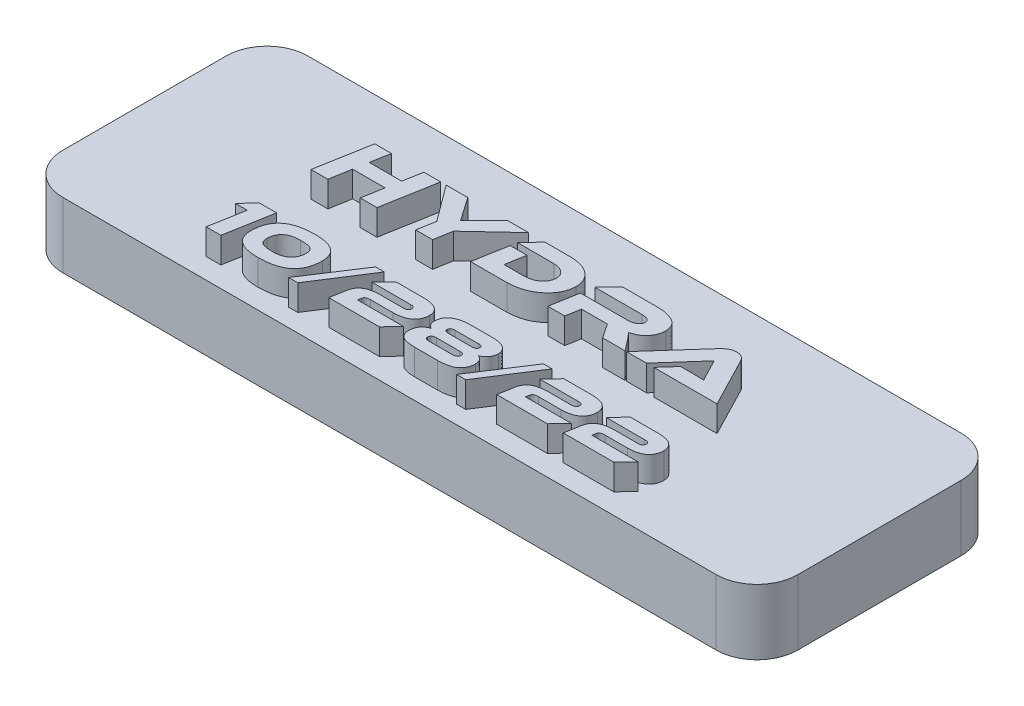
from build123d import *

# Parameters (mm, degrees)
SKETCH1_W           = 57.15
SKETCH1_H           = 19.05
BOSS_EXTRUDE1_DEPTH = 5.08
FILLET1_R           = 3.175
BOSS_EXTRUDE2_DEPTH = 2
SKETCH4_R           = 0.9
CUT_EXTRUDE1_DEPTH  = 4


with BuildPart() as part:
    # Sketch1 → Boss-Extrude1 (new body)
    with BuildSketch(Plane(origin=(0, 0, 0), x_dir=(1, 0, 0), z_dir=(0, 1, 0))):
        Rectangle(SKETCH1_W, SKETCH1_H)
    extrude(amount=BOSS_EXTRUDE1_DEPTH)

    # Fillet1
    fillet1_edges = [part.edges().sort_by_distance(p)[0] for p in [
        (-28.575, 2.54, -9.525),
        (-28.575, 2.54, 9.525),
        (28.575, 2.54, 9.525),
        (28.575, 2.54, -9.525),
    ]]
    fillet(fillet1_edges, radius=FILLET1_R)

    # Sketch3 → Boss-Extrude2 (add)
    with BuildSketch(Plane(origin=(0, 5.08, 0), x_dir=(1, 0, 0), z_dir=(0, 1, 0))):
        with BuildLine():
            Line((15.936649786, 0.006075914), (13.971522732, 3.800574494))
            add(Edge.make_bspline(
                [(13.971522732, 3.800574494), (13.953401788, 3.832806008), (13.917443125, 3.896765269), (13.852569435, 3.985575321), (13.775309948, 4.0630874), (13.690407037, 4.133983071), (13.592601143, 4.192399523), (13.480489993, 4.23493807), (13.354448166, 4.260058315), (13.265717233, 4.264204191), (13.219589517, 4.266359469)],
                knots=[0, 0, 0, 0, 0.000110886, 0.000220038, 0.000328642, 0.000438436, 0.000551159, 0.000668641, 0.000796469, 0.000934872, 0.000934872, 0.000934872, 0.000934872], degree=3))
            add(Edge.make_bspline(
                [(13.219589517, 4.266359469), (13.169777857, 4.264009128), (13.073046736, 4.259444915), (12.933007981, 4.230967468), (12.802729419, 4.187726952), (12.682994543, 4.126959855), (12.573312888, 4.055096369), (12.470111534, 3.977511138), (12.375805321, 3.892229282), (12.318422818, 3.830720556), (12.2898943, 3.800140628)],
                knots=[0, 0, 0, 0, 0.00014941, 0.000290146, 0.000427171, 0.000560039, 0.000691642, 0.000820174, 0.000947034, 0.001072464, 0.001072464, 0.001072464, 0.001072464], degree=3))
            Line((12.2898943, 3.800140628), (8.903896053, 0.006075914))
            Line((8.903896053, 0.006075914), (10.451986498, 0.006075914))
            Line((10.451986498, 0.006075914), (12.928931208, 2.798493231))
            Line((12.928931208, 2.798493231), (13.491298758, 1.696826253))
            add(Edge.make_bspline(
                [(13.491298758, 1.696826253), (13.517972762, 1.644325557), (13.572489009, 1.5370248), (13.641917351, 1.403208105), (13.698000445, 1.297464771), (13.739141559, 1.223921613), (13.775545401, 1.155498073), (13.800843706, 1.112747401), (13.812875845, 1.092414734)],
                knots=[0, 0, 0, 0, 0.000176664, 0.000361065, 0.000452265, 0.000535729, 0.000613867, 0.000684736, 0.000684736, 0.000684736, 0.000684736], degree=3))
            add(Edge.make_bspline(
                [(13.812875845, 1.092414734), (13.757427501, 1.095166522), (13.639267666, 1.101030553), (13.45483713, 1.103502684), (13.259818264, 1.10564963), (13.127565667, 1.105358474), (13.061440773, 1.105212899)],
                knots=[0, 0, 0, 0, 0.000166537, 0.000354888, 0.000553268, 0.00075164, 0.00075164, 0.00075164, 0.00075164], degree=3))
            Line((13.061440773, 1.105212899), (12.006395678, 1.105536066))
            Line((12.006395678, 1.105536066), (11.020672783, 0.006075914))
            Line((11.020672783, 0.006075914), (15.936649786, 0.006075914))
        make_face()
        with BuildLine():
            add(Edge.make_bspline(
                [(8.155110601, 0.821261664), (8.127324476, 0.855514425), (8.074414905, 0.920737585), (8.000629565, 1.014147602), (7.932026379, 1.094728322), (7.871660288, 1.165931133), (7.815679153, 1.228233858), (7.764174777, 1.283693514), (7.715591894, 1.332710365), (7.683288019, 1.361916294), (7.667928696, 1.375802657)],
                knots=[0, 0, 0, 0, 0.000132319, 0.000251958, 0.000357066, 0.000449775, 0.000531993, 0.000608312, 0.000676831, 0.00073894, 0.00073894, 0.00073894, 0.00073894], degree=3))
            add(Edge.make_bspline(
                [(7.667928696, 1.375802657), (7.718373618, 1.387655917), (7.817706328, 1.41099655), (7.961673348, 1.456505146), (8.09751208, 1.512656797), (8.225481623, 1.577599655), (8.346268229, 1.650662326), (8.457992649, 1.734287933), (8.561730528, 1.827209607), (8.657285995, 1.928008098), (8.74315281, 2.036209783), (8.819366418, 2.148795776), (8.882612688, 2.26744033), (8.936278633, 2.389702633), (8.976781015, 2.517720245), (9.008934795, 2.649747841), (9.02654449, 2.787111939), (9.030675934, 2.88015474), (9.032761498, 2.927122995)],
                knots=[0, 0, 0, 0, 0.000155422, 0.000306047, 0.000452383, 0.000595882, 0.000736201, 0.000875336, 0.001013884, 0.001153561, 0.001291475, 0.00142788, 0.00156081, 0.001694289, 0.00182785, 0.001963107, 0.002101444, 0.002242464, 0.002242464, 0.002242464, 0.002242464], degree=3))
            add(Edge.make_bspline(
                [(9.032761498, 2.927122995), (9.028097851, 2.986733362), (9.01909889, 3.101757358), (8.982692723, 3.266295736), (8.930107082, 3.416602664), (8.859145617, 3.55250609), (8.770617398, 3.674215745), (8.662815655, 3.779555576), (8.539470115, 3.872802597), (8.397838356, 3.946152329), (8.248044709, 4.009923214), (8.093755339, 4.066098529), (7.935637523, 4.111445148), (7.77464989, 4.149301444), (7.610082555, 4.17747869), (7.442540316, 4.196572697), (7.271932823, 4.207081738), (7.157234264, 4.20637971), (7.099324541, 4.206025266)],
                knots=[0, 0, 0, 0, 0.000179195, 0.000345775, 0.000503934, 0.000655634, 0.000804102, 0.000953423, 0.00110627, 0.001266195, 0.001430402, 0.00159465, 0.001758393, 0.001923592, 0.002090563, 0.002258951, 0.002429281, 0.002602973, 0.002602973, 0.002602973, 0.002602973], degree=3))
            Line((7.099324541, 4.206025266), (4.382824906, 4.206347541))
            Line((4.382824906, 4.206347541), (3.333914646, 3.106887389))
            Line((3.333914646, 3.106887389), (7.011419293, 3.106887389))
            add(Edge.make_bspline(
                [(7.011419293, 3.106887389), (7.059380843, 3.105563142), (7.150192599, 3.103055777), (7.27829741, 3.084102014), (7.389917703, 3.053127658), (7.484277277, 3.008361144), (7.560443595, 2.950733271), (7.616180007, 2.878524615), (7.649406671, 2.792039639), (7.653172018, 2.729960255), (7.655130531, 2.697670193)],
                knots=[0, 0, 0, 0, 0.000143839, 0.000272348, 0.000387495, 0.000490117, 0.000583924, 0.00067132, 0.000760449, 0.00085706, 0.00085706, 0.00085706, 0.00085706], degree=3))
            add(Edge.make_bspline(
                [(7.655130531, 2.697670193), (7.653453492, 2.677195647), (7.650145501, 2.636809238), (7.637364263, 2.578009425), (7.617255786, 2.522994029), (7.589864845, 2.47158108), (7.556473468, 2.423095084), (7.514536534, 2.378841184), (7.465518398, 2.338813063), (7.391840184, 2.288346001), (7.287225806, 2.236864834), (7.149746628, 2.191707585), (6.999141191, 2.165412454), (6.894656266, 2.161339559), (6.840618792, 2.15923314)],
                knots=[0, 0, 0, 0, 6.1582e-05, 0.000121471, 0.000179891, 0.000236731, 0.000295819, 0.000355966, 0.000418937, 0.000485369, 0.000623551, 0.000766937, 0.000918284, 0.001080402, 0.001080402, 0.001080402, 0.001080402], degree=3))
            Line((6.840618792, 2.15923314), (3.16330876, 2.159459893))
            Line((3.16330876, 2.159459893), (2.784184569, 0.003655726))
            Line((2.784184569, 0.003655726), (4.092163026, 0.003655726))
            Line((4.092163026, 0.003655726), (4.288043858, 1.11686837))
            Line((4.288043858, 1.11686837), (6.297402068, 1.11686837))
            Line((6.297402068, 1.11686837), (7.043012975, 0.003655726))
            Line((7.043012975, 0.003655726), (8.793302988, 0.003655726))
            Line((8.793302988, 0.003655726), (8.155110601, 0.821261664))
        make_face()
        with BuildLine():
            add(Edge.make_bspline(
                [(2.55867763, 2.425376215), (2.555801916, 2.490366785), (2.550151506, 2.618064917), (2.518344126, 2.803986167), (2.469713518, 2.980115123), (2.404179951, 3.146960648), (2.317982795, 3.303299496), (2.214551164, 3.450058323), (2.092308783, 3.586303096), (1.95374969, 3.712179584), (1.798742287, 3.825344313), (1.630327922, 3.925395962), (1.448112387, 4.009390478), (1.25324885, 4.079106767), (1.045179008, 4.133528035), (0.823979956, 4.173811565), (0.589540311, 4.198189582), (0.428794296, 4.203371321), (0.346464589, 4.206025266)],
                knots=[0, 0, 0, 0, 0.000195009, 0.000383167, 0.000564368, 0.00074244, 0.000919581, 0.001098646, 0.001279935, 0.00146761, 0.001659228, 0.001854731, 0.002054318, 0.002260196, 0.002474835, 0.002698788, 0.00293411, 0.003181175, 0.003181175, 0.003181175, 0.003181175], degree=3))
            Line((0.346464589, 4.206025266), (-1.649600884, 4.206347541))
            Line((-1.649600884, 4.206347541), (-2.679554935, 3.106887389))
            Line((-2.679554935, 3.106887389), (0.151239021, 3.106887389))
            add(Edge.make_bspline(
                [(0.151239021, 3.106887389), (0.190750921, 3.105364711), (0.267967163, 3.102389015), (0.380588809, 3.089591847), (0.487281825, 3.069582481), (0.588130182, 3.04202105), (0.683492268, 3.008030543), (0.771622667, 2.964107485), (0.854485945, 2.914773344), (0.931249281, 2.858665576), (0.999163961, 2.795181395), (1.060842489, 2.72884043), (1.110672717, 2.655711823), (1.153486551, 2.579167986), (1.187717263, 2.49778013), (1.210713003, 2.411231968), (1.227244218, 2.320728819), (1.229970936, 2.258648084), (1.231366232, 2.22688058)],
                knots=[0, 0, 0, 0, 0.000118592, 0.000231759, 0.000339692, 0.000443921, 0.000545141, 0.000642853, 0.0007388, 0.00083424, 0.000927403, 0.001017368, 0.001105364, 0.001192113, 0.001280223, 0.00136938, 0.001460305, 0.001555592, 0.001555592, 0.001555592, 0.001555592], degree=3))
            add(Edge.make_bspline(
                [(1.231366232, 2.22688058), (1.228921788, 2.185642711), (1.224127048, 2.104755276), (1.201586347, 1.98706422), (1.168080093, 1.87545354), (1.120952623, 1.770616802), (1.061706994, 1.672112744), (0.991418602, 1.579018173), (0.906839413, 1.493971369), (0.812401326, 1.414841832), (0.708184046, 1.343689091), (0.596529197, 1.281927096), (0.478895742, 1.227960987), (0.353625987, 1.185692043), (0.222464649, 1.150471437), (0.084116555, 1.126576329), (-0.060210252, 1.109169924), (-0.15900863, 1.106548421), (-0.209341401, 1.105212899)],
                knots=[0, 0, 0, 0, 0.00012382, 0.000242871, 0.000358539, 0.000472706, 0.000586683, 0.000702784, 0.000821729, 0.000945681, 0.001071953, 0.001199634, 0.001328098, 0.001459638, 0.001595783, 0.001735109, 0.00188048, 0.002031451, 0.002031451, 0.002031451, 0.002031451], degree=3))
            Line((-0.209341401, 1.105212899), (-1.725425722, 1.105536066))
            Line((-1.725425722, 1.105536066), (-1.453720052, 2.623662059))
            Line((-1.453720052, 2.623662059), (-2.761698509, 2.623662059))
            Line((-2.761698509, 2.623662059), (-3.229285011, 0.006075914))
            Line((-3.229285011, 0.006075914), (-0.398491055, 0.006075914))
            add(Edge.make_bspline(
                [(-0.398491055, 0.006075914), (-0.296623679, 0.00973645), (-0.096467742, 0.016928919), (0.196909938, 0.055361686), (0.477503471, 0.113609118), (0.745379994, 0.192345638), (1.00082206, 0.290947451), (1.242998592, 0.411678855), (1.473449233, 0.551302588), (1.652823715, 0.685730436), (1.788110055, 0.801137626), (1.883300669, 0.891127884), (1.972791218, 0.98286194), (2.055684535, 1.077854124), (2.132445982, 1.175378809), (2.202621649, 1.275986307), (2.26734959, 1.378755373), (2.324479922, 1.484675691), (2.376054975, 1.592866707), (2.420943245, 1.703675086), (2.459150184, 1.817381495), (2.492247599, 1.933500983), (2.519103778, 2.052449268), (2.537580931, 2.174419147), (2.552013189, 2.298802205), (2.555862909, 2.38285802), (2.55867763, 2.425376215)],
                knots=[0, 0, 0, 0, 0.000305659, 0.00060058, 0.000886364, 0.001164634, 0.001437273, 0.001706688, 0.001975409, 0.002244537, 0.002378097, 0.002508729, 0.002637378, 0.002762417, 0.002886772, 0.003009517, 0.003130255, 0.003250927, 0.003370328, 0.003489667, 0.003609348, 0.003730019, 0.003851781, 0.003974869, 0.004099948, 0.004227226, 0.004227226, 0.004227226, 0.004227226], degree=3))
        make_face()
        with BuildLine():
            Line((-4.567350224, 4.208766837), (-5.736316477, 3.045937203))
            add(Edge.make_bspline(
                [(-5.736316477, 3.045937203), (-5.778994085, 3.002996199), (-5.859188805, 2.922306534), (-5.971803651, 2.808525621), (-6.070005467, 2.710170076), (-6.152996059, 2.624049414), (-6.224224472, 2.54963655), (-6.28673006, 2.48596507), (-6.339765089, 2.429919868), (-6.372273024, 2.395395347), (-6.387198116, 2.379544396)],
                knots=[0, 0, 0, 0, 0.000181625, 0.000341288, 0.000480267, 0.000598575, 0.000700079, 0.000789292, 0.000866239, 0.000931555, 0.000931555, 0.000931555, 0.000931555], degree=3))
            add(Edge.make_bspline(
                [(-6.387198116, 2.379544396), (-6.399005631, 2.400004032), (-6.425311188, 2.445585352), (-6.470825966, 2.520103953), (-6.530223445, 2.605177377), (-6.596015271, 2.700257958), (-6.66366472, 2.796857317), (-6.727383556, 2.887031312), (-6.784321541, 2.96668259), (-6.819605422, 3.016396767), (-6.836048019, 3.03956401)],
                knots=[0, 0, 0, 0, 7.0869e-05, 0.000157887, 0.000261844, 0.000382044, 0.000504789, 0.000615628, 0.000713289, 0.000798516, 0.000798516, 0.000798516, 0.000798516], degree=3))
            Line((-6.836048019, 3.03956401), (-7.644574903, 4.208766837))
            Line((-7.644574903, 4.208766837), (-9.325358814, 4.208766837))
            Line((-9.325358814, 4.208766837), (-7.246494503, 1.399082354))
            Line((-7.246494503, 1.399082354), (-7.492925226, 0.003655726))
            Line((-7.492925226, 0.003655726), (-6.178628033, 0.003655726))
            Line((-6.178628033, 0.003655726), (-5.938516046, 1.392796648))
            Line((-5.938516046, 1.392796648), (-2.924478732, 4.208766837))
            Line((-2.924478732, 4.208766837), (-4.567350224, 4.208766837))
        make_face()
        Polygon((-9.749790791, 4.208766837), (-11.057769248, 4.208766837), (-11.323156181, 2.743700198), (-13.844332048, 2.743700198), (-13.572626378, 4.208766837), (-14.880604835, 4.208766837), (-15.632534479, 0.003655726), (-14.318237286, 0.003655726), (-14.033894143, 1.644240046), (-11.512718276, 1.644240046), (-11.803380156, 0.003655726), (-10.501720435, 0.003655726), align=None)
        with BuildLine():
            Line((12.547539263, -5.218973535), (15.538671157, -5.218973535))
            add(Edge.make_bspline(
                [(15.538671157, -5.218973535), (15.566372071, -5.218922741), (15.618218446, -5.218827674), (15.690947449, -5.225918073), (15.75247149, -5.242216387), (15.804302027, -5.26353583), (15.844395417, -5.294908436), (15.872709416, -5.334273792), (15.890261393, -5.381008794), (15.891486093, -5.4147712), (15.892120459, -5.432259348)],
                knots=[0, 0, 0, 0, 8.3099e-05, 0.000155531, 0.000218392, 0.000273538, 0.000322508, 0.000368908, 0.000417497, 0.000469711, 0.000469711, 0.000469711, 0.000469711], degree=3))
            add(Edge.make_bspline(
                [(15.892120459, -5.432259348), (15.891480666, -5.458018948), (15.890271061, -5.506720508), (15.869708675, -5.573936821), (15.836422299, -5.630194031), (15.787208676, -5.673414306), (15.723677577, -5.704561408), (15.64594341, -5.726311626), (15.552818251, -5.738498194), (15.485816606, -5.73961472), (15.449783907, -5.740215175)],
                knots=[0, 0, 0, 0, 7.6993e-05, 0.000145564, 0.000208395, 0.000270703, 0.000339032, 0.00041902, 0.000511893, 0.000619952, 0.000619952, 0.000619952, 0.000619952], degree=3))
            Line((15.449783907, -5.740215175), (13.692020413, -5.739416071))
            add(Edge.make_bspline(
                [(13.692020413, -5.739416071), (13.636418257, -5.740560639), (13.528165095, -5.742789025), (13.370169769, -5.753609346), (13.221450409, -5.772857955), (13.081827541, -5.798779792), (12.951564343, -5.833149331), (12.830485491, -5.875619954), (12.718218111, -5.92500466), (12.615016243, -5.98174212), (12.521547046, -6.047028209), (12.437021553, -6.120143527), (12.361620944, -6.201107035), (12.295619922, -6.289606037), (12.239238349, -6.385733808), (12.192142594, -6.489539314), (12.153195231, -6.600822081), (12.135873555, -6.678800473), (12.127060513, -6.718474855)],
                knots=[0, 0, 0, 0, 0.000166829, 0.000324804, 0.000474816, 0.000616477, 0.000750546, 0.000878553, 0.001001026, 0.001118108, 0.001231277, 0.001342418, 0.001452782, 0.001562526, 0.00167296, 0.001786425, 0.001904052, 0.002025887, 0.002025887, 0.002025887, 0.002025887], degree=3))
            Line((12.127060513, -6.718474855), (11.911716402, -7.932183575))
            Line((11.911716402, -7.932183575), (15.848289246, -7.932183575))
            Line((15.848289246, -7.932183575), (16.755027935, -6.970155942))
            Line((16.755027935, -6.970155942), (13.183362124, -6.970155942))
            Line((13.183362124, -6.970155942), (13.233122174, -6.707239748))
            add(Edge.make_bspline(
                [(13.233122174, -6.707239748), (13.236899698, -6.686112106), (13.244222455, -6.645156023), (13.272933808, -6.590591717), (13.311294501, -6.543848716), (13.362633832, -6.508043577), (13.423709299, -6.47963759), (13.496026919, -6.461031101), (13.57909034, -6.450993538), (13.638013851, -6.450679637), (13.669239306, -6.450513291)],
                knots=[0, 0, 0, 0, 6.4036e-05, 0.000124134, 0.000182613, 0.000243892, 0.000310094, 0.000383827, 0.000466868, 0.000560486, 0.000560486, 0.000560486, 0.000560486], degree=3))
            Line((13.669239306, -6.450513291), (15.428093268, -6.449714187))
            add(Edge.make_bspline(
                [(15.428093268, -6.449714187), (15.493774293, -6.448593152), (15.621108734, -6.446419826), (15.805006583, -6.426694059), (15.976423193, -6.400940141), (16.134270079, -6.361961645), (16.280024073, -6.315052912), (16.411365328, -6.255202462), (16.530838443, -6.187512089), (16.635550883, -6.107690588), (16.728134075, -6.020066732), (16.808590437, -5.925525662), (16.876369321, -5.823724541), (16.932122123, -5.715194429), (16.974258093, -5.599220599), (17.004953528, -5.476792913), (17.022608874, -5.347458364), (17.024561827, -5.259004345), (17.02555788, -5.21389067)],
                knots=[0, 0, 0, 0, 0.00019697, 0.000381861, 0.000554393, 0.000716581, 0.000869107, 0.001013024, 0.00114885, 0.001280192, 0.001406932, 0.001530654, 0.001651783, 0.001773055, 0.001895792, 0.002021116, 0.002151095, 0.002286391, 0.002286391, 0.002286391, 0.002286391], degree=3))
            add(Edge.make_bspline(
                [(17.02555788, -5.21389067), (17.025105426, -5.1780961), (17.024219681, -5.108023129), (17.008009834, -5.005989197), (16.984017761, -4.909275966), (16.947483058, -4.818686266), (16.899848705, -4.734234215), (16.841769663, -4.655338408), (16.773402037, -4.582231577), (16.694107596, -4.515185386), (16.60328468, -4.455053695), (16.499706059, -4.402688892), (16.383472939, -4.359688685), (16.255285459, -4.322394884), (16.11448245, -4.294289614), (15.961135405, -4.27367202), (15.795268874, -4.26108405), (15.680439258, -4.258543735), (15.620959354, -4.257227893)],
                knots=[0, 0, 0, 0, 0.000107259, 0.000209975, 0.000309113, 0.00040566, 0.000501999, 0.00059927, 0.000698874, 0.0008016, 0.000910084, 0.001024914, 0.001148961, 0.001281358, 0.001425053, 0.00157924, 0.00174531, 0.001923772, 0.001923772, 0.001923772, 0.001923772], degree=3))
            Line((15.620959354, -4.257227893), (13.454277952, -4.256945902))
            Line((13.454277952, -4.256945902), (12.547539263, -5.218973535))
        make_face()
        with BuildLine():
            Line((7.377080905, -5.218973535), (10.3682128, -5.218973535))
            add(Edge.make_bspline(
                [(10.3682128, -5.218973535), (10.395913714, -5.218922741), (10.447760088, -5.218827674), (10.520489091, -5.225918073), (10.582013133, -5.242216387), (10.63384367, -5.26353583), (10.673937059, -5.294908436), (10.702251058, -5.334273792), (10.719803036, -5.381008794), (10.721027735, -5.4147712), (10.721662101, -5.432259348)],
                knots=[0, 0, 0, 0, 8.3099e-05, 0.000155531, 0.000218392, 0.000273538, 0.000322508, 0.000368908, 0.000417497, 0.000469711, 0.000469711, 0.000469711, 0.000469711], degree=3))
            add(Edge.make_bspline(
                [(10.721662101, -5.432259348), (10.721022308, -5.458018948), (10.719812703, -5.506720508), (10.699250318, -5.573936821), (10.665963942, -5.630194031), (10.616750318, -5.673414306), (10.55321922, -5.704561408), (10.475485053, -5.726311626), (10.382359893, -5.738498194), (10.315358249, -5.73961472), (10.27932555, -5.740215175)],
                knots=[0, 0, 0, 0, 7.6993e-05, 0.000145564, 0.000208395, 0.000270703, 0.000339032, 0.00041902, 0.000511893, 0.000619952, 0.000619952, 0.000619952, 0.000619952], degree=3))
            Line((10.27932555, -5.740215175), (8.521562055, -5.739416071))
            add(Edge.make_bspline(
                [(8.521562055, -5.739416071), (8.465959899, -5.740560639), (8.357706737, -5.742789025), (8.199711411, -5.753609346), (8.050992051, -5.772857955), (7.911369183, -5.798779792), (7.781105985, -5.833149331), (7.660027133, -5.875619954), (7.547759753, -5.92500466), (7.444557885, -5.98174212), (7.351088689, -6.047028209), (7.266563196, -6.120143527), (7.191162587, -6.201107035), (7.125161564, -6.289606037), (7.068779991, -6.385733808), (7.021684236, -6.489539314), (6.982736873, -6.600822081), (6.965415197, -6.678800473), (6.956602156, -6.718474855)],
                knots=[0, 0, 0, 0, 0.000166829, 0.000324804, 0.000474816, 0.000616477, 0.000750546, 0.000878553, 0.001001026, 0.001118108, 0.001231277, 0.001342418, 0.001452782, 0.001562526, 0.00167296, 0.001786425, 0.001904052, 0.002025887, 0.002025887, 0.002025887, 0.002025887], degree=3))
            Line((6.956602156, -6.718474855), (6.741258044, -7.932183575))
            Line((6.741258044, -7.932183575), (10.677830889, -7.932183575))
            Line((10.677830889, -7.932183575), (11.584569577, -6.970155942))
            Line((11.584569577, -6.970155942), (8.012903767, -6.970155942))
            Line((8.012903767, -6.970155942), (8.062663817, -6.707239748))
            add(Edge.make_bspline(
                [(8.062663817, -6.707239748), (8.06644134, -6.686112106), (8.073764097, -6.645156023), (8.10247545, -6.590591717), (8.140836143, -6.543848716), (8.192175475, -6.508043577), (8.253250942, -6.47963759), (8.325568562, -6.461031101), (8.408631983, -6.450993538), (8.467555493, -6.450679637), (8.498780948, -6.450513291)],
                knots=[0, 0, 0, 0, 6.4036e-05, 0.000124134, 0.000182613, 0.000243892, 0.000310094, 0.000383827, 0.000466868, 0.000560486, 0.000560486, 0.000560486, 0.000560486], degree=3))
            Line((8.498780948, -6.450513291), (10.257634911, -6.449714187))
            add(Edge.make_bspline(
                [(10.257634911, -6.449714187), (10.323315936, -6.448593152), (10.450650376, -6.446419826), (10.634548225, -6.426694059), (10.805964836, -6.400940141), (10.963811722, -6.361961645), (11.109565715, -6.315052912), (11.24090697, -6.255202462), (11.360380086, -6.187512089), (11.465092525, -6.107690588), (11.557675717, -6.020066732), (11.638132079, -5.925525662), (11.705910963, -5.823724541), (11.761663765, -5.715194429), (11.803799735, -5.599220599), (11.834495171, -5.476792913), (11.852150516, -5.347458364), (11.85410347, -5.259004345), (11.855099523, -5.21389067)],
                knots=[0, 0, 0, 0, 0.00019697, 0.000381861, 0.000554393, 0.000716581, 0.000869107, 0.001013024, 0.00114885, 0.001280192, 0.001406932, 0.001530654, 0.001651783, 0.001773055, 0.001895792, 0.002021116, 0.002151095, 0.002286391, 0.002286391, 0.002286391, 0.002286391], degree=3))
            add(Edge.make_bspline(
                [(11.855099523, -5.21389067), (11.854647068, -5.1780961), (11.853761323, -5.108023129), (11.837551476, -5.005989197), (11.813559404, -4.909275966), (11.777024701, -4.818686266), (11.729390348, -4.734234215), (11.671311306, -4.655338408), (11.602943679, -4.582231577), (11.523649239, -4.515185386), (11.432826322, -4.455053695), (11.329247701, -4.402688892), (11.213014581, -4.359688685), (11.084827102, -4.322394884), (10.944024093, -4.294289614), (10.790677047, -4.27367202), (10.624810516, -4.26108405), (10.509980901, -4.258543735), (10.450500996, -4.257227893)],
                knots=[0, 0, 0, 0, 0.000107259, 0.000209975, 0.000309113, 0.00040566, 0.000501999, 0.00059927, 0.000698874, 0.0008016, 0.000910084, 0.001024914, 0.001148961, 0.001281358, 0.001425053, 0.00157924, 0.00174531, 0.001923772, 0.001923772, 0.001923772, 0.001923772], degree=3))
            Line((10.450500996, -4.257227893), (8.283819594, -4.256945902))
            Line((8.283819594, -4.256945902), (7.377080905, -5.218973535))
        make_face()
        Polygon((6.491270465, -4.05005839), (3.826343343, -8.139071868), (4.539570726, -8.139071868), (7.165795587, -4.05005839), align=None)
        with BuildLine():
            add(Edge.make_bspline(
                [(2.145109496, -7.932183575), (2.186771054, -7.931231171), (2.268740703, -7.929357303), (2.389381902, -7.92303202), (2.504838313, -7.913299393), (2.615078713, -7.901630571), (2.71983482, -7.886120178), (2.819756863, -7.869023985), (2.914134147, -7.848038176), (3.003008373, -7.824924016), (3.086720734, -7.79951071), (3.165025248, -7.770456276), (3.238821837, -7.739757788), (3.306770407, -7.705166947), (3.369767071, -7.668342595), (3.427192994, -7.628415757), (3.479544276, -7.586096005), (3.540828281, -7.52618861), (3.608893469, -7.44788067), (3.679627769, -7.349322028), (3.738550042, -7.24731168), (3.785064676, -7.14179993), (3.820734635, -7.033385143), (3.843950971, -6.921252912), (3.855400575, -6.805633592), (3.853837653, -6.727559312), (3.853047325, -6.688079215)],
                knots=[0, 0, 0, 0, 0.000125013, 0.000245965, 0.000362345, 0.000472585, 0.000578466, 0.000679988, 0.000776639, 0.000868406, 0.000955443, 0.001038954, 0.001118882, 0.001195077, 0.00126751, 0.001337627, 0.001404712, 0.001469201, 0.001594487, 0.00171546, 0.001832632, 0.001947228, 0.002060803, 0.002174381, 0.002290108, 0.002408491, 0.002408491, 0.002408491, 0.002408491], degree=3))
            add(Edge.make_bspline(
                [(3.853047325, -6.688079215), (3.851078427, -6.645013118), (3.847289314, -6.562133096), (3.82207087, -6.444672392), (3.783411556, -6.339091581), (3.727319812, -6.248261694), (3.65963707, -6.170723555), (3.581913799, -6.10705473), (3.495368629, -6.055649416), (3.431736146, -6.034755311), (3.399512379, -6.024174444)],
                knots=[0, 0, 0, 0, 0.000129139, 0.000248525, 0.000358904, 0.000464809, 0.000566844, 0.000666291, 0.000765209, 0.000866693, 0.000866693, 0.000866693, 0.000866693], degree=3))
            add(Edge.make_bspline(
                [(3.399512379, -6.024174444), (3.440843035, -6.009960653), (3.524127185, -5.981318874), (3.640587349, -5.914739414), (3.750314358, -5.831227741), (3.835139045, -5.748532962), (3.896530116, -5.672798575), (3.937857181, -5.610121102), (3.971944913, -5.541280496), (4.001590849, -5.468161351), (4.025102653, -5.389726388), (4.041155488, -5.306040388), (4.053866343, -5.217443624), (4.056480977, -5.156345524), (4.057817953, -5.125103406)],
                knots=[0, 0, 0, 0, 0.000130881, 0.000263734, 0.000400196, 0.000543864, 0.000617818, 0.000692362, 0.000768557, 0.000847875, 0.000928857, 0.001013724, 0.001103318, 0.001197072, 0.001197072, 0.001197072, 0.001197072], degree=3))
            add(Edge.make_bspline(
                [(4.057817953, -5.125103406), (4.056597618, -5.090349443), (4.05422499, -5.022779311), (4.035525317, -4.92500398), (4.009013255, -4.833420282), (3.971040329, -4.748206931), (3.921670533, -4.670138756), (3.862202391, -4.59864822), (3.79215361, -4.533829851), (3.712283076, -4.475835581), (3.622758665, -4.424616933), (3.524902512, -4.38005075), (3.419062792, -4.341545727), (3.304813196, -4.310438157), (3.1823421, -4.286642109), (3.051645869, -4.270305953), (2.913087684, -4.259700382), (2.818015937, -4.258066688), (2.76920279, -4.257227893)],
                knots=[0, 0, 0, 0, 0.000104182, 0.000202555, 0.000297711, 0.000389729, 0.000481385, 0.000573968, 0.000667919, 0.000766953, 0.000869442, 0.000976817, 0.001089166, 0.001206956, 0.001331669, 0.001463128, 0.001601898, 0.001748332, 0.001748332, 0.001748332, 0.001748332], degree=3))
            Line((2.76920279, -4.257227893), (1.01721503, -4.256945902))
            add(Edge.make_bspline(
                [(1.01721503, -4.256945902), (0.955941016, -4.257933345), (0.83660449, -4.259856478), (0.662243978, -4.27445031), (0.497678332, -4.298184588), (0.342659552, -4.330928531), (0.197262899, -4.372216855), (0.061486281, -4.423370326), (-0.064498068, -4.48435463), (-0.18071126, -4.553771073), (-0.286111226, -4.631408275), (-0.376959488, -4.719750309), (-0.455817934, -4.815062538), (-0.51919052, -4.920560106), (-0.569956029, -5.033834732), (-0.606698648, -5.155860959), (-0.630309498, -5.286067538), (-0.634542773, -5.375899516), (-0.636708671, -5.421860839)],
                knots=[0, 0, 0, 0, 0.000183805, 0.000357976, 0.000524491, 0.000682313, 0.000832949, 0.000977498, 0.00111702, 0.001252279, 0.00138314, 0.001508725, 0.001631528, 0.001753207, 0.001876737, 0.002003, 0.002134641, 0.002272556, 0.002272556, 0.002272556, 0.002272556], degree=3))
            add(Edge.make_bspline(
                [(-0.636708671, -5.421860839), (-0.63454772, -5.460637769), (-0.630411686, -5.534856314), (-0.607913743, -5.640394087), (-0.572075057, -5.734319484), (-0.522817108, -5.816044843), (-0.462991867, -5.884580779), (-0.397584596, -5.942717951), (-0.327188617, -5.991372439), (-0.275336168, -6.0132839), (-0.249564203, -6.024174444)],
                knots=[0, 0, 0, 0, 0.00011638, 0.00022275, 0.000322273, 0.000416653, 0.000507404, 0.000594091, 0.000678837, 0.000762581, 0.000762581, 0.000762581, 0.000762581], degree=3))
            add(Edge.make_bspline(
                [(-0.249564203, -6.024174444), (-0.274492837, -6.030958114), (-0.324187423, -6.044481183), (-0.396278839, -6.072159226), (-0.465864167, -6.104472842), (-0.532014141, -6.143792742), (-0.596032025, -6.187363466), (-0.65698228, -6.237488578), (-0.715424172, -6.292639194), (-0.770726444, -6.353238645), (-0.821146824, -6.419812547), (-0.866395401, -6.491713486), (-0.9036059, -6.570185197), (-0.936076116, -6.65334551), (-0.960708094, -6.742945011), (-0.978474962, -6.837982222), (-0.992133682, -6.93861072), (-0.994593337, -7.007719051), (-0.995857156, -7.043228273)],
                knots=[0, 0, 0, 0, 7.7461e-05, 0.000154416, 0.000231347, 0.000307349, 0.000385003, 0.000463457, 0.000543805, 0.000625913, 0.000709263, 0.000794051, 0.000880268, 0.000969397, 0.001061581, 0.001158529, 0.001259331, 0.001365863, 0.001365863, 0.001365863, 0.001365863], degree=3))
            add(Edge.make_bspline(
                [(-0.995857156, -7.043228273), (-0.995683574, -7.074984833), (-0.995343954, -7.137117687), (-0.984211543, -7.228477712), (-0.962534643, -7.315193082), (-0.930943849, -7.397544917), (-0.890189923, -7.475819019), (-0.83833687, -7.548574193), (-0.777655132, -7.617378923), (-0.707142651, -7.681696438), (-0.624318167, -7.740249013), (-0.52763156, -7.790386011), (-0.416776155, -7.832290641), (-0.292755542, -7.868255087), (-0.154662788, -7.895907325), (-0.00305442, -7.91498255), (0.162118788, -7.929258288), (0.276993361, -7.931522719), (0.336751697, -7.932700688)],
                knots=[0, 0, 0, 0, 9.5217e-05, 0.000186295, 0.000275341, 0.00036269, 0.000450349, 0.000539338, 0.000630011, 0.000725141, 0.000825008, 0.000933418, 0.001050917, 0.001180018, 0.001320418, 0.001472913, 0.00163825, 0.001817512, 0.001817512, 0.001817512, 0.001817512], degree=3))
            Line((0.336751697, -7.932700688), (2.145109496, -7.932183575))
        make_face()
        with BuildLine():
            add(Edge.make_bspline(
                [(2.404967535, -6.449714187), (2.430437371, -6.450481454), (2.478051966, -6.451915822), (2.544504681, -6.462295382), (2.600923953, -6.478314967), (2.647587422, -6.501735345), (2.683827744, -6.532597578), (2.709821348, -6.570559095), (2.723592408, -6.615980043), (2.724650811, -6.647995141), (2.7252091, -6.664882542)],
                knots=[0, 0, 0, 0, 7.6381e-05, 0.000142791, 0.000201248, 0.000251692, 0.000298195, 0.000342566, 0.000387849, 0.000438401, 0.000438401, 0.000438401, 0.000438401], degree=3))
            add(Edge.make_bspline(
                [(2.7252091, -6.664882542), (2.72472975, -6.688226141), (2.723813939, -6.732824723), (2.704630488, -6.795373302), (2.67300346, -6.849206592), (2.626604123, -6.892724618), (2.567904987, -6.927750857), (2.494991366, -6.950290013), (2.410248545, -6.966886823), (2.349095634, -6.969202952), (2.316467729, -6.970438714)],
                knots=[0, 0, 0, 0, 6.9755e-05, 0.000133269, 0.000193903, 0.000254998, 0.000322079, 0.000397205, 0.000482702, 0.000580498, 0.000580498, 0.000580498, 0.000580498], degree=3))
            Line((2.316467729, -6.970438714), (0.503027846, -6.970155942))
            add(Edge.make_bspline(
                [(0.503027846, -6.970155942), (0.477958078, -6.969487722), (0.431006837, -6.968236265), (0.3656643, -6.958046297), (0.310251126, -6.941463094), (0.264106671, -6.918653153), (0.228371272, -6.887523732), (0.203689356, -6.849203004), (0.188473476, -6.804370639), (0.187621435, -6.772197033), (0.187173152, -6.755269577)],
                knots=[0, 0, 0, 0, 7.5181e-05, 0.000140801, 0.000197728, 0.000248171, 0.000294073, 0.000338001, 0.000383531, 0.000434082, 0.000434082, 0.000434082, 0.000434082], degree=3))
            add(Edge.make_bspline(
                [(0.187173152, -6.755269577), (0.187405459, -6.731951284), (0.187848684, -6.687461638), (0.20589386, -6.624978081), (0.237466624, -6.571485588), (0.282859669, -6.527263189), (0.342188911, -6.493624141), (0.414098975, -6.470524019), (0.49815109, -6.45409962), (0.558761255, -6.451761428), (0.591115211, -6.450513291)],
                knots=[0, 0, 0, 0, 6.9705e-05, 0.000132992, 0.000192528, 0.000254182, 0.000320856, 0.000395224, 0.000479936, 0.000576934, 0.000576934, 0.000576934, 0.000576934], degree=3))
            Line((0.591115211, -6.450513291), (2.404967535, -6.449714187))
        make_face(mode=Mode.SUBTRACT)
        with BuildLine():
            add(Edge.make_bspline(
                [(2.648238891, -5.218973535), (2.666204811, -5.219198427), (2.701204722, -5.219636544), (2.751837565, -5.228301012), (2.799565423, -5.240368296), (2.842334763, -5.25971699), (2.880707309, -5.28343921), (2.907857297, -5.318095563), (2.92538999, -5.359573023), (2.928401771, -5.389948541), (2.929979728, -5.405863134)],
                knots=[0, 0, 0, 0, 5.3815e-05, 0.000104839, 0.000153737, 0.000201004, 0.000245375, 0.000287473, 0.000330852, 0.000378591, 0.000378591, 0.000378591, 0.000378591], degree=3))
            add(Edge.make_bspline(
                [(2.929979728, -5.405863134), (2.928120891, -5.430297574), (2.924607345, -5.476483199), (2.90298802, -5.54029414), (2.866660799, -5.591806118), (2.817638725, -5.630011869), (2.76035837, -5.656042763), (2.698027685, -5.675598553), (2.630430707, -5.68684283), (2.58367063, -5.687754153), (2.55963285, -5.688222633)],
                knots=[0, 0, 0, 0, 7.3319e-05, 0.000138587, 0.0001994, 0.000259737, 0.000322704, 0.000387218, 0.000455335, 0.000527396, 0.000527396, 0.000527396, 0.000527396], degree=3))
            Line((2.55963285, -5.688222633), (0.713125835, -5.688222633))
            add(Edge.make_bspline(
                [(0.713125835, -5.688222633), (0.694549494, -5.688204865), (0.658675233, -5.688170553), (0.606996264, -5.679717041), (0.559134892, -5.66640895), (0.516267677, -5.646675592), (0.477991279, -5.620784393), (0.452403107, -5.58249431), (0.434539254, -5.537200648), (0.432316831, -5.503647002), (0.431138158, -5.485851661)],
                knots=[0, 0, 0, 0, 5.5643e-05, 0.000107457, 0.00015657, 0.000204168, 0.000248805, 0.000292972, 0.000340064, 0.000393243, 0.000393243, 0.000393243, 0.000393243], degree=3))
            add(Edge.make_bspline(
                [(0.431138158, -5.485851661), (0.433267546, -5.462204608), (0.437293894, -5.417491619), (0.459576263, -5.356065551), (0.497417283, -5.307302147), (0.547814603, -5.272336123), (0.605187261, -5.247888578), (0.666937491, -5.229757796), (0.732929575, -5.220335185), (0.778261657, -5.219776221), (0.801485036, -5.219489867)],
                knots=[0, 0, 0, 0, 7.1041e-05, 0.000134328, 0.000193048, 0.00025321, 0.000316233, 0.00037952, 0.00044581, 0.000515441, 0.000515441, 0.000515441, 0.000515441], degree=3))
            Line((0.801485036, -5.219489867), (2.648238891, -5.218973535))
        make_face(mode=Mode.SUBTRACT)
        with BuildLine():
            Line((-5.677046631, -5.218973535), (-2.685914737, -5.218973535))
            add(Edge.make_bspline(
                [(-2.685914737, -5.218973535), (-2.658213823, -5.218922741), (-2.606367448, -5.218827674), (-2.533638445, -5.225918073), (-2.472114403, -5.242216387), (-2.420283867, -5.26353583), (-2.380190477, -5.294908436), (-2.351876478, -5.334273792), (-2.3343245, -5.381008794), (-2.333099801, -5.4147712), (-2.332465435, -5.432259348)],
                knots=[0, 0, 0, 0, 8.3099e-05, 0.000155531, 0.000218392, 0.000273538, 0.000322508, 0.000368908, 0.000417497, 0.000469711, 0.000469711, 0.000469711, 0.000469711], degree=3))
            add(Edge.make_bspline(
                [(-2.332465435, -5.432259348), (-2.333105228, -5.458018948), (-2.334314833, -5.506720508), (-2.354877218, -5.573936821), (-2.388163595, -5.630194031), (-2.437377218, -5.673414306), (-2.500908317, -5.704561408), (-2.578642483, -5.726311626), (-2.671767643, -5.738498194), (-2.738769287, -5.73961472), (-2.774801987, -5.740215175)],
                knots=[0, 0, 0, 0, 7.6993e-05, 0.000145564, 0.000208395, 0.000270703, 0.000339032, 0.00041902, 0.000511893, 0.000619952, 0.000619952, 0.000619952, 0.000619952], degree=3))
            Line((-2.774801987, -5.740215175), (-4.532565481, -5.739416071))
            add(Edge.make_bspline(
                [(-4.532565481, -5.739416071), (-4.588167637, -5.740560639), (-4.696420799, -5.742789025), (-4.854416125, -5.753609346), (-5.003135485, -5.772857955), (-5.142758353, -5.798779792), (-5.273021551, -5.833149331), (-5.394100403, -5.875619954), (-5.506367783, -5.92500466), (-5.609569651, -5.98174212), (-5.703038848, -6.047028209), (-5.787564341, -6.120143527), (-5.86296495, -6.201107035), (-5.928965972, -6.289606037), (-5.985347545, -6.385733808), (-6.0324433, -6.489539314), (-6.071390663, -6.600822081), (-6.088712339, -6.678800473), (-6.09752538, -6.718474855)],
                knots=[0, 0, 0, 0, 0.000166829, 0.000324804, 0.000474816, 0.000616477, 0.000750546, 0.000878553, 0.001001026, 0.001118108, 0.001231277, 0.001342418, 0.001452782, 0.001562526, 0.00167296, 0.001786425, 0.001904052, 0.002025887, 0.002025887, 0.002025887, 0.002025887], degree=3))
            Line((-6.09752538, -6.718474855), (-6.312869492, -7.932183575))
            Line((-6.312869492, -7.932183575), (-2.376296648, -7.932183575))
            Line((-2.376296648, -7.932183575), (-1.469557959, -6.970155942))
            Line((-1.469557959, -6.970155942), (-5.04122377, -6.970155942))
            Line((-5.04122377, -6.970155942), (-4.99146372, -6.707239748))
            add(Edge.make_bspline(
                [(-4.99146372, -6.707239748), (-4.987686196, -6.686112106), (-4.980363439, -6.645156023), (-4.951652086, -6.590591717), (-4.913291393, -6.543848716), (-4.861952061, -6.508043577), (-4.800876595, -6.47963759), (-4.728558975, -6.461031101), (-4.645495553, -6.450993538), (-4.586572043, -6.450679637), (-4.555346588, -6.450513291)],
                knots=[0, 0, 0, 0, 6.4036e-05, 0.000124134, 0.000182613, 0.000243892, 0.000310094, 0.000383827, 0.000466868, 0.000560486, 0.000560486, 0.000560486, 0.000560486], degree=3))
            Line((-4.555346588, -6.450513291), (-2.796492625, -6.449714187))
            add(Edge.make_bspline(
                [(-2.796492625, -6.449714187), (-2.7308116, -6.448593152), (-2.60347716, -6.446419826), (-2.419579311, -6.426694059), (-2.248162701, -6.400940141), (-2.090315814, -6.361961645), (-1.944561821, -6.315052912), (-1.813220566, -6.255202462), (-1.69374745, -6.187512089), (-1.589035011, -6.107690588), (-1.496451819, -6.020066732), (-1.415995457, -5.925525662), (-1.348216573, -5.823724541), (-1.292463771, -5.715194429), (-1.250327801, -5.599220599), (-1.219632365, -5.476792913), (-1.20197702, -5.347458364), (-1.200024067, -5.259004345), (-1.199028013, -5.21389067)],
                knots=[0, 0, 0, 0, 0.00019697, 0.000381861, 0.000554393, 0.000716581, 0.000869107, 0.001013024, 0.00114885, 0.001280192, 0.001406932, 0.001530654, 0.001651783, 0.001773055, 0.001895792, 0.002021116, 0.002151095, 0.002286391, 0.002286391, 0.002286391, 0.002286391], degree=3))
            add(Edge.make_bspline(
                [(-1.199028013, -5.21389067), (-1.199480468, -5.1780961), (-1.200366213, -5.108023129), (-1.21657606, -5.005989197), (-1.240568133, -4.909275966), (-1.277102836, -4.818686266), (-1.324737188, -4.734234215), (-1.38281623, -4.655338408), (-1.451183857, -4.582231577), (-1.530478297, -4.515185386), (-1.621301214, -4.455053695), (-1.724879835, -4.402688892), (-1.841112955, -4.359688685), (-1.969300434, -4.322394884), (-2.110103443, -4.294289614), (-2.263450489, -4.27367202), (-2.42931702, -4.26108405), (-2.544146636, -4.258543735), (-2.60362654, -4.257227893)],
                knots=[0, 0, 0, 0, 0.000107259, 0.000209975, 0.000309113, 0.00040566, 0.000501999, 0.00059927, 0.000698874, 0.0008016, 0.000910084, 0.001024914, 0.001148961, 0.001281358, 0.001425053, 0.00157924, 0.00174531, 0.001923772, 0.001923772, 0.001923772, 0.001923772], degree=3))
            Line((-2.60362654, -4.257227893), (-4.770307942, -4.256945902))
            Line((-4.770307942, -4.256945902), (-5.677046631, -5.218973535))
        make_face()
        Polygon((-6.562857071, -4.05005839), (-9.227784193, -8.139071868), (-8.51455681, -8.139071868), (-5.888331949, -4.05005839), align=None)
        with BuildLine():
            add(Edge.make_bspline(
                [(-11.097492568, -4.205753245), (-11.154593924, -4.20639815), (-11.266925995, -4.207666832), (-11.432637421, -4.213805403), (-11.592648208, -4.225246011), (-11.747161811, -4.240095428), (-11.896056588, -4.260037206), (-12.039273934, -4.284920981), (-12.177185514, -4.313802188), (-12.309734541, -4.346120038), (-12.43654845, -4.383749272), (-12.557485677, -4.426552533), (-12.673508308, -4.472224962), (-12.783362582, -4.524117338), (-12.888431274, -4.578873484), (-12.98744757, -4.638857599), (-13.080922205, -4.703243715), (-13.168736215, -4.771965987), (-13.251594448, -4.844826576), (-13.328588089, -4.922821718), (-13.400153052, -5.005043307), (-13.467562685, -5.090962924), (-13.527671445, -5.18251662), (-13.584263316, -5.277290921), (-13.633429384, -5.377585075), (-13.679557356, -5.480915677), (-13.718430981, -5.589719203), (-13.752811699, -5.702636581), (-13.782622701, -5.819692193), (-13.805477653, -5.941608197), (-13.824076792, -6.06752364), (-13.83638564, -6.198094357), (-13.844936287, -6.332815699), (-13.845650743, -6.424102975), (-13.846013949, -6.470510423)],
                knots=[0, 0, 0, 0, 0.000171312, 0.000337012, 0.00049738, 0.000652505, 0.000802621, 0.000947932, 0.001088493, 0.001225264, 0.001357119, 0.001485126, 0.001610044, 0.001730996, 0.001849428, 0.001965345, 0.002078058, 0.002189744, 0.002299681, 0.002408844, 0.002518253, 0.002626572, 0.002736165, 0.002846598, 0.002957491, 0.003071033, 0.00318591, 0.003303822, 0.003425073, 0.003548063, 0.003675777, 0.003806785, 0.003941403, 0.004080604, 0.004080604, 0.004080604, 0.004080604], degree=3))
            add(Edge.make_bspline(
                [(-13.846013949, -6.470510423), (-13.844656296, -6.532725476), (-13.842022556, -6.653417738), (-13.816635434, -6.827938058), (-13.776112215, -6.990047106), (-13.719317837, -7.14024227), (-13.645372126, -7.277956037), (-13.554811534, -7.403136721), (-13.448481224, -7.515956622), (-13.32542367, -7.616000774), (-13.185937375, -7.702745849), (-13.031317552, -7.779438213), (-12.860204909, -7.842507446), (-12.673646353, -7.895609169), (-12.470830944, -7.935791135), (-12.252250064, -7.964127031), (-12.017741185, -7.98091947), (-11.856194446, -7.982880129), (-11.772711341, -7.983893345)],
                knots=[0, 0, 0, 0, 0.000186545, 0.000361882, 0.000527754, 0.000687003, 0.000842323, 0.000995285, 0.001149196, 0.001306104, 0.001469661, 0.00164101, 0.001823006, 0.002015943, 0.002222385, 0.002442644, 0.002676813, 0.00292724, 0.00292724, 0.00292724, 0.00292724], degree=3))
            add(Edge.make_bspline(
                [(-11.772711341, -7.983893345), (-11.715913777, -7.983380019), (-11.604415707, -7.98237232), (-11.439824875, -7.975990544), (-11.28081022, -7.965003258), (-11.126954836, -7.948680913), (-10.978502896, -7.929266178), (-10.83586393, -7.904105738), (-10.69859718, -7.875596387), (-10.567095566, -7.841995411), (-10.440746312, -7.804464931), (-10.32020933, -7.761989808), (-10.204671053, -7.715814846), (-10.094875717, -7.664606669), (-9.990897707, -7.608490903), (-9.891979069, -7.548339608), (-9.798606252, -7.483895632), (-9.710896925, -7.414499954), (-9.628492076, -7.341424669), (-9.552491185, -7.262809113), (-9.479902501, -7.18190029), (-9.414373346, -7.094705032), (-9.353694995, -7.003516426), (-9.297283929, -6.908219643), (-9.247121727, -6.808134503), (-9.202184005, -6.703993625), (-9.163092543, -6.595424725), (-9.128422258, -6.482622195), (-9.100100242, -6.364960314), (-9.075864133, -6.243348255), (-9.057458181, -6.117331748), (-9.045083168, -5.986773695), (-9.036607247, -5.851777937), (-9.035875086, -5.760225753), (-9.035503961, -5.713818961)],
                knots=[0, 0, 0, 0, 0.000170392, 0.000334494, 0.000494064, 0.000648473, 0.00079859, 0.000943113, 0.001082891, 0.001219081, 0.001350169, 0.001478176, 0.001602352, 0.001723304, 0.001841405, 0.001956639, 0.002070464, 0.002181522, 0.00229199, 0.002400592, 0.0025094, 0.002617866, 0.002727459, 0.002837893, 0.002949859, 0.003063082, 0.00317796, 0.003295871, 0.003416929, 0.003540857, 0.00366778, 0.003798788, 0.003934205, 0.004073405, 0.004073405, 0.004073405, 0.004073405], degree=3))
            add(Edge.make_bspline(
                [(-9.035503961, -5.713818961), (-9.036845617, -5.651864372), (-9.039453747, -5.53142685), (-9.065166312, -5.357329546), (-9.104353798, -5.194951682), (-9.161379265, -5.045253766), (-9.234747382, -4.907894424), (-9.324002483, -4.782830639), (-9.430107289, -4.670804764), (-9.551728093, -4.570938519), (-9.690276203, -4.484275151), (-9.844465898, -4.409545186), (-10.014344103, -4.345204255), (-10.200271504, -4.293863202), (-10.402202674, -4.25419887), (-10.619664309, -4.225768444), (-10.85337795, -4.209016704), (-11.014391821, -4.207051109), (-11.097492568, -4.205753245)],
                knots=[0, 0, 0, 0, 0.000185746, 0.000361083, 0.00052676, 0.000686009, 0.000840246, 0.000992741, 0.001145521, 0.00130181, 0.001463587, 0.001634583, 0.001815083, 0.002007802, 0.002212518, 0.002431984, 0.002665356, 0.002914983, 0.002914983, 0.002914983, 0.002914983], degree=3))
        make_face()
        with BuildLine():
            add(Edge.make_bspline(
                [(-11.606150857, -7.021348599), (-11.652343937, -7.021854174), (-11.741498472, -7.022829956), (-11.870413467, -7.017591194), (-11.98975893, -7.009340097), (-12.099520029, -6.995853431), (-12.199784071, -6.977791428), (-12.290327403, -6.954558851), (-12.371666629, -6.92776808), (-12.443874445, -6.89577873), (-12.507865807, -6.85746675), (-12.561892378, -6.809228041), (-12.60846209, -6.753532905), (-12.645012401, -6.688452997), (-12.674147466, -6.615916979), (-12.69360827, -6.534816355), (-12.705920425, -6.445830998), (-12.706616019, -6.383634321), (-12.706977331, -6.351327518)],
                knots=[0, 0, 0, 0, 0.000138565, 0.000267436, 0.000386943, 0.000497368, 0.000599032, 0.000692348, 0.000777591, 0.00085564, 0.000928899, 0.001000308, 0.001071897, 0.001145712, 0.001223247, 0.001305698, 0.001395292, 0.001492131, 0.001492131, 0.001492131, 0.001492131], degree=3))
            add(Edge.make_bspline(
                [(-12.706977331, -6.351327518), (-12.705440478, -6.304070169), (-12.70245039, -6.212126705), (-12.68378845, -6.079013736), (-12.654533007, -5.954439253), (-12.612715189, -5.839274516), (-12.560657561, -5.731825667), (-12.495447339, -5.634468641), (-12.419631469, -5.545120744), (-12.331685921, -5.466071948), (-12.233712846, -5.395226287), (-12.125110368, -5.334487382), (-12.006729832, -5.283435533), (-11.879136226, -5.240941797), (-11.741803255, -5.208296683), (-11.594933394, -5.185693562), (-11.438399176, -5.170762309), (-11.330677858, -5.169135367), (-11.275182705, -5.16829721)],
                knots=[0, 0, 0, 0, 0.000141763, 0.000275812, 0.0004025, 0.000524963, 0.000642655, 0.000759791, 0.000875529, 0.00099331, 0.001113634, 0.001237554, 0.001365798, 0.001499859, 0.001640517, 0.001788722, 0.001945363, 0.002111808, 0.002111808, 0.002111808, 0.002111808], degree=3))
            add(Edge.make_bspline(
                [(-11.275182705, -5.16829721), (-11.229054056, -5.168009724), (-11.139975736, -5.167454564), (-11.010825424, -5.171313587), (-10.891214291, -5.17974049), (-10.781277205, -5.193477036), (-10.680983998, -5.210588071), (-10.590272242, -5.232796313), (-10.50907794, -5.25982086), (-10.436793152, -5.291687778), (-10.373167559, -5.330152418), (-10.318772193, -5.377160874), (-10.273184897, -5.432670471), (-10.236260354, -5.496790682), (-10.207411038, -5.569240936), (-10.187984013, -5.650050065), (-10.175548487, -5.738759012), (-10.174886108, -5.80069376), (-10.17454058, -5.833001866)],
                knots=[0, 0, 0, 0, 0.00013838, 0.000267224, 0.000387529, 0.000497953, 0.000599476, 0.000692596, 0.00077784, 0.000855889, 0.000929147, 0.001000031, 0.001070493, 0.001143616, 0.001221151, 0.001303602, 0.001392403, 0.001489242, 0.001489242, 0.001489242, 0.001489242], degree=3))
            add(Edge.make_bspline(
                [(-10.17454058, -5.833001866), (-10.176078099, -5.880258006), (-10.179069484, -5.972199119), (-10.197758319, -6.105585977), (-10.227119268, -6.230260661), (-10.267821933, -6.346409008), (-10.32082409, -6.453739693), (-10.386241351, -6.551573704), (-10.461885361, -6.64153852), (-10.549527362, -6.721564153), (-10.647942309, -6.791879743), (-10.755487193, -6.854243117), (-10.874036532, -6.904835069), (-11.001676664, -6.947243215), (-11.138871838, -6.980841995), (-11.285973402, -7.004512108), (-11.442864151, -7.019068958), (-11.550843781, -7.020761541), (-11.606150857, -7.021348599)],
                knots=[0, 0, 0, 0, 0.000141763, 0.000275812, 0.000403278, 0.000525472, 0.000644235, 0.000761371, 0.000877718, 0.000996039, 0.001116363, 0.001239983, 0.001368227, 0.001502288, 0.001643134, 0.001791467, 0.001948904, 0.002115349, 0.002115349, 0.002115349, 0.002115349], degree=3))
        make_face(mode=Mode.SUBTRACT)
        Polygon((-16.269427276, -5.218973535), (-15.368217482, -5.218973535), (-15.849231298, -7.93430124), (-14.704750148, -7.93430124), (-14.04681171, -4.256945902), (-15.401390848, -4.256945902), align=None)
    extrude(amount=BOSS_EXTRUDE2_DEPTH)

    # Sketch4 → Cut-Extrude1 (cut)
    with BuildSketch(Plane.XZ):
        with Locations((-25.4, 0)):
            Circle(SKETCH4_R)
        with Locations((25.4, 0)):
            Circle(SKETCH4_R)
    extrude(amount=-CUT_EXTRUDE1_DEPTH, mode=Mode.SUBTRACT)


solid = part.part
